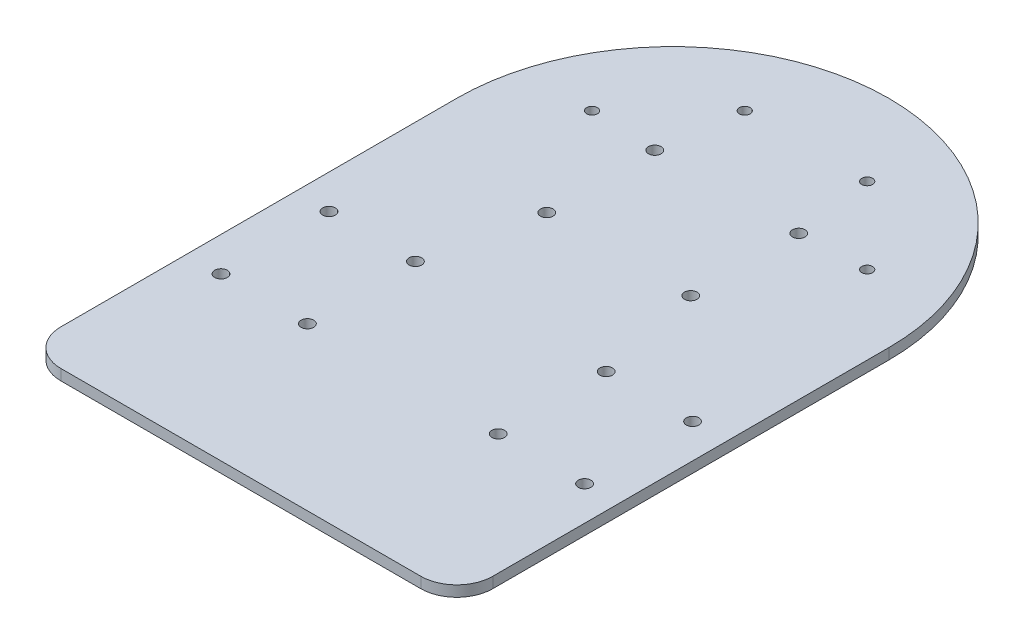
from build123d import *

# Parameters (mm, degrees)
BOSS_EXTRUDE3_DEPTH = 3
FILLET3_R           = 10
SKETCH4_R           = 1.75
CUT_EXTRUDE1_DEPTH  = 3
CUT_EXTRUDE2_REACH  = 5
SKETCH5_R           = 1.75
CUT_EXTRUDE3_REACH  = 5
SKETCH6_R           = 1.5


with BuildPart() as part:
    # Sketch1 → Boss-Extrude3 (new body)
    with BuildSketch(Plane(origin=(0, 0, 0), x_dir=(1, 0, 0), z_dir=(0, 1, 0))):
        with BuildLine():
            Line((-60, 60), (-60, -60))
            Line((-60, -60), (60, -60))
            Line((60, -60), (60, 60))
            ThreePointArc((60, 60), (0, 120), (-60, 60))
        make_face()
    extrude(amount=BOSS_EXTRUDE3_DEPTH)

    # Fillet3
    fillet3_edges = [part.edges().sort_by_distance(p)[0] for p in [
        (60, 1.5, 60),
        (-60, 1.5, 60),
    ]]
    fillet(fillet3_edges, radius=FILLET3_R)

    # Sketch4 → Cut-Extrude1 (cut)
    with BuildSketch(Plane(origin=(0, 3, 0), x_dir=(1, 0, 0), z_dir=(0, 1, 0))):
        with Locations((-26.5, -15)):
            Circle(SKETCH4_R)
        with Locations((-50.5, -15)):
            Circle(SKETCH4_R)
        with Locations((-50.5, 15)):
            Circle(SKETCH4_R)
        with Locations((-26.5, 15)):
            Circle(SKETCH4_R)
    cut_extrude1 = extrude(amount=-CUT_EXTRUDE1_DEPTH, mode=Mode.SUBTRACT)

    # Mirror1: Cut-Extrude1 across plane
    add(cut_extrude1.mirror(Plane(origin=(0, 0, 0), x_dir=(0, 0, 1), z_dir=(1, 0, 0))), mode=Mode.SUBTRACT)

    # Sketch5 → Cut-Extrude2 (cut, up to next)
    with BuildSketch(Plane(origin=(0, 3, 0), x_dir=(1, 0, 0), z_dir=(0, 1, 0)), mode=Mode.PRIVATE) as cut_extrude2_sk1:
        with Locations((20, 75)):
            Circle(SKETCH5_R)
    cut_extrude2_tool1 = extrude(cut_extrude2_sk1.sketch, amount=-CUT_EXTRUDE2_REACH, mode=Mode.PRIVATE) & part.part
    add(cut_extrude2_tool1.solids().sort_by_distance((20, 3, -75))[0], mode=Mode.SUBTRACT)
    # Sketch5 → Cut-Extrude2 (cut, up to next)
    with BuildSketch(Plane(origin=(0, 3, 0), x_dir=(1, 0, 0), z_dir=(0, 1, 0)), mode=Mode.PRIVATE) as cut_extrude2_sk2:
        with Locations((-20, 75)):
            Circle(SKETCH5_R)
    cut_extrude2_tool2 = extrude(cut_extrude2_sk2.sketch, amount=-CUT_EXTRUDE2_REACH, mode=Mode.PRIVATE) & part.part
    add(cut_extrude2_tool2.solids().sort_by_distance((-20, 3, -75))[0], mode=Mode.SUBTRACT)
    # Sketch5 → Cut-Extrude2 (cut, up to next)
    with BuildSketch(Plane(origin=(0, 3, 0), x_dir=(1, 0, 0), z_dir=(0, 1, 0)), mode=Mode.PRIVATE) as cut_extrude2_sk3:
        with Locations((-20, 45)):
            Circle(SKETCH5_R)
    cut_extrude2_tool3 = extrude(cut_extrude2_sk3.sketch, amount=-CUT_EXTRUDE2_REACH, mode=Mode.PRIVATE) & part.part
    add(cut_extrude2_tool3.solids().sort_by_distance((-20, 3, -45))[0], mode=Mode.SUBTRACT)
    # Sketch5 → Cut-Extrude2 (cut, up to next)
    with BuildSketch(Plane(origin=(0, 3, 0), x_dir=(1, 0, 0), z_dir=(0, 1, 0)), mode=Mode.PRIVATE) as cut_extrude2_sk4:
        with Locations((20, 45)):
            Circle(SKETCH5_R)
    cut_extrude2_tool4 = extrude(cut_extrude2_sk4.sketch, amount=-CUT_EXTRUDE2_REACH, mode=Mode.PRIVATE) & part.part
    add(cut_extrude2_tool4.solids().sort_by_distance((20, 3, -45))[0], mode=Mode.SUBTRACT)

    # Sketch6 → Cut-Extrude3 (cut, up to next)
    with BuildSketch(Plane(origin=(0, 3, 0), x_dir=(1, 0, 0), z_dir=(0, 1, 0)), mode=Mode.PRIVATE) as cut_extrude3_sk1:
        with Locations((-38.213203436, 75.786796564)):
            Circle(SKETCH6_R)
    cut_extrude3_tool1 = extrude(cut_extrude3_sk1.sketch, amount=-CUT_EXTRUDE3_REACH, mode=Mode.PRIVATE) & part.part
    add(cut_extrude3_tool1.solids().sort_by_distance((-38.213203, 3, -75.786797))[0], mode=Mode.SUBTRACT)
    # Sketch6 → Cut-Extrude3 (cut, up to next)
    with BuildSketch(Plane(origin=(0, 3, 0), x_dir=(1, 0, 0), z_dir=(0, 1, 0)), mode=Mode.PRIVATE) as cut_extrude3_sk2:
        with Locations((-17, 97)):
            Circle(SKETCH6_R)
    cut_extrude3_tool2 = extrude(cut_extrude3_sk2.sketch, amount=-CUT_EXTRUDE3_REACH, mode=Mode.PRIVATE) & part.part
    add(cut_extrude3_tool2.solids().sort_by_distance((-17, 3, -97))[0], mode=Mode.SUBTRACT)
    # Sketch6 → Cut-Extrude3 (cut, up to next)
    with BuildSketch(Plane(origin=(0, 3, 0), x_dir=(1, 0, 0), z_dir=(0, 1, 0)), mode=Mode.PRIVATE) as cut_extrude3_sk3:
        with Locations((17, 97)):
            Circle(SKETCH6_R)
    cut_extrude3_tool3 = extrude(cut_extrude3_sk3.sketch, amount=-CUT_EXTRUDE3_REACH, mode=Mode.PRIVATE) & part.part
    add(cut_extrude3_tool3.solids().sort_by_distance((17, 3, -97))[0], mode=Mode.SUBTRACT)
    # Sketch6 → Cut-Extrude3 (cut, up to next)
    with BuildSketch(Plane(origin=(0, 3, 0), x_dir=(1, 0, 0), z_dir=(0, 1, 0)), mode=Mode.PRIVATE) as cut_extrude3_sk4:
        with Locations((38.213203436, 75.786796564)):
            Circle(SKETCH6_R)
    cut_extrude3_tool4 = extrude(cut_extrude3_sk4.sketch, amount=-CUT_EXTRUDE3_REACH, mode=Mode.PRIVATE) & part.part
    add(cut_extrude3_tool4.solids().sort_by_distance((38.213203, 3, -75.786797))[0], mode=Mode.SUBTRACT)


solid = part.part
